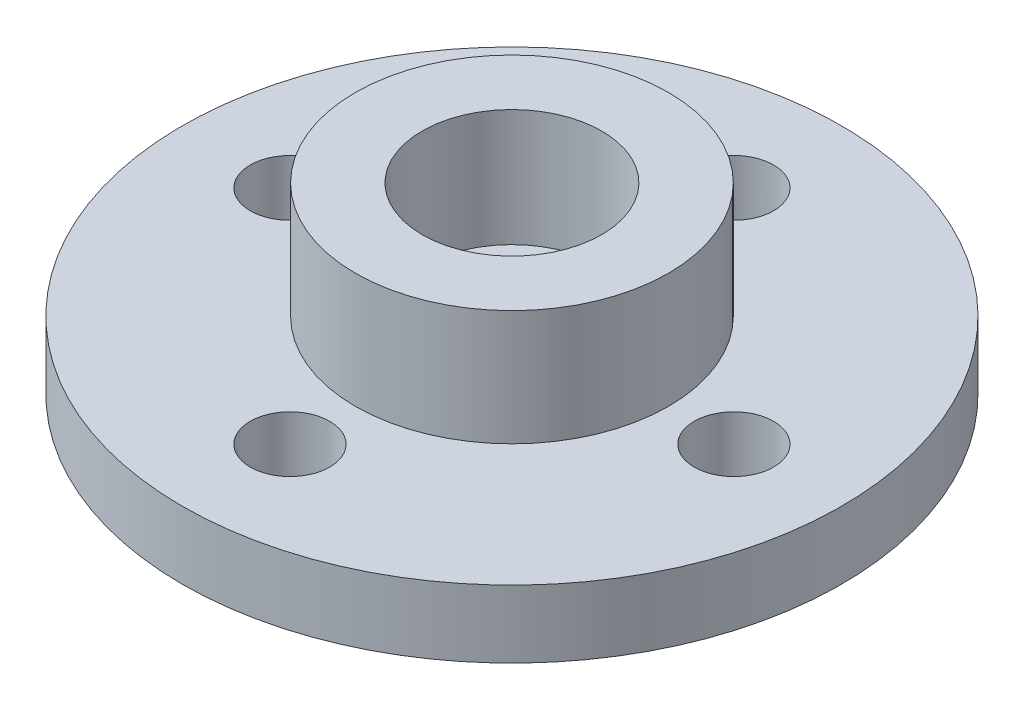
from build123d import *

# Parameters (mm, degrees)
SKETCH1_R           = 10
BOSS_EXTRUDE1_DEPTH = 2.05
SKETCH2_R           = 4.75
BOSS_EXTRUDE2_DEPTH = 3.5
SKETCH3_R           = 2.725
CUT_EXTRUDE1_DEPTH  = 3.55
SKETCH4_R           = 1.375
CUT_EXTRUDE2_DEPTH  = 3.55
SKETCH5_R           = 1.205
CUT_EXTRUDE3_DEPTH  = 3.55
CIRPATTERN1_COUNT   = 4


with BuildPart() as part:
    # Sketch1 → Boss-Extrude1 (new body)
    with BuildSketch(Plane(origin=(0, 0, 0), x_dir=(1, 0, 0), z_dir=(0, 1, 0))):
        Circle(SKETCH1_R)
    extrude(amount=BOSS_EXTRUDE1_DEPTH)

    # Sketch2 → Boss-Extrude2 (add)
    with BuildSketch(Plane(origin=(0, 2.05, 0), x_dir=(1, 0, 0), z_dir=(0, 1, 0))):
        Circle(SKETCH2_R)
    extrude(amount=BOSS_EXTRUDE2_DEPTH)

    # Sketch3 → Cut-Extrude1 (cut)
    with BuildSketch(Plane(origin=(0, 5.55, 0), x_dir=(1, 0, 0), z_dir=(0, 1, 0))):
        Circle(SKETCH3_R)
    extrude(amount=-CUT_EXTRUDE1_DEPTH, mode=Mode.SUBTRACT)

    # Sketch4 → Cut-Extrude2 (cut)
    with BuildSketch(Plane(origin=(0, 2, 0), x_dir=(1, 0, 0), z_dir=(0, 1, 0))):
        Circle(SKETCH4_R)
    extrude(amount=-CUT_EXTRUDE2_DEPTH, mode=Mode.SUBTRACT)

    # Sketch5 → Cut-Extrude3 (cut)
    with BuildSketch(Plane.XZ):
        with Locations((-6.735, 0)):
            Circle(SKETCH5_R)
    cut_extrude3 = extrude(amount=-CUT_EXTRUDE3_DEPTH, mode=Mode.SUBTRACT)

    # CirPattern1: Cut-Extrude3 ×4 about axis
    cirpattern1_axis = Axis((0, 0, 0), (0, 1, 0))
    for i in range(1, CIRPATTERN1_COUNT):
        add(cut_extrude3.rotate(cirpattern1_axis, i * 360 / CIRPATTERN1_COUNT), mode=Mode.SUBTRACT)


solid = part.part
